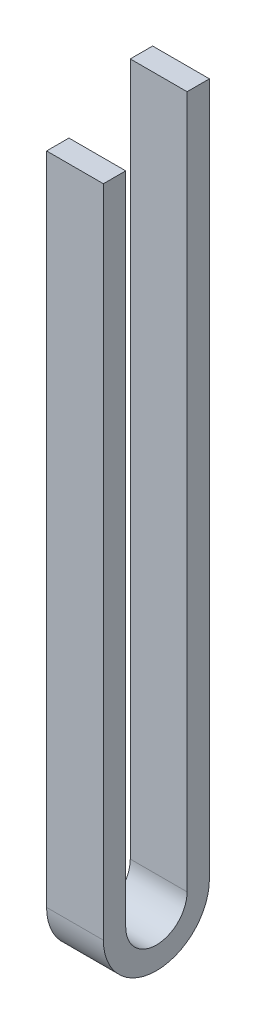
from build123d import *

# Parameters (mm, degrees)
BOSS_EXTRUDE1_DEPTH = 38.1


with BuildPart() as part:
    # Sketch1 → Boss-Extrude1 (new body)
    with BuildSketch(Plane(origin=(0, 0, 0), x_dir=(0, 0, -1), z_dir=(1, 0, 0))):
        with BuildLine():
            Line((0, 0), (0, -439.442482619))
            ThreePointArc((0, -439.442482619), (35.56, -475.002482619), (71.12, -439.442482619))
            Line((71.12, -439.442482619), (71.12, 25.4))
            Line((71.12, 25.4), (56.134, 25.4))
            Line((56.134, 25.4), (56.134, -439.442482619))
            ThreePointArc((56.134, -439.442482619), (35.56, -460.016482619), (14.986, -439.442482619))
            Line((14.986, -439.442482619), (14.986, 0))
            Line((14.986, 0), (0, 0))
        make_face()
    extrude(amount=BOSS_EXTRUDE1_DEPTH)


solid = part.part
